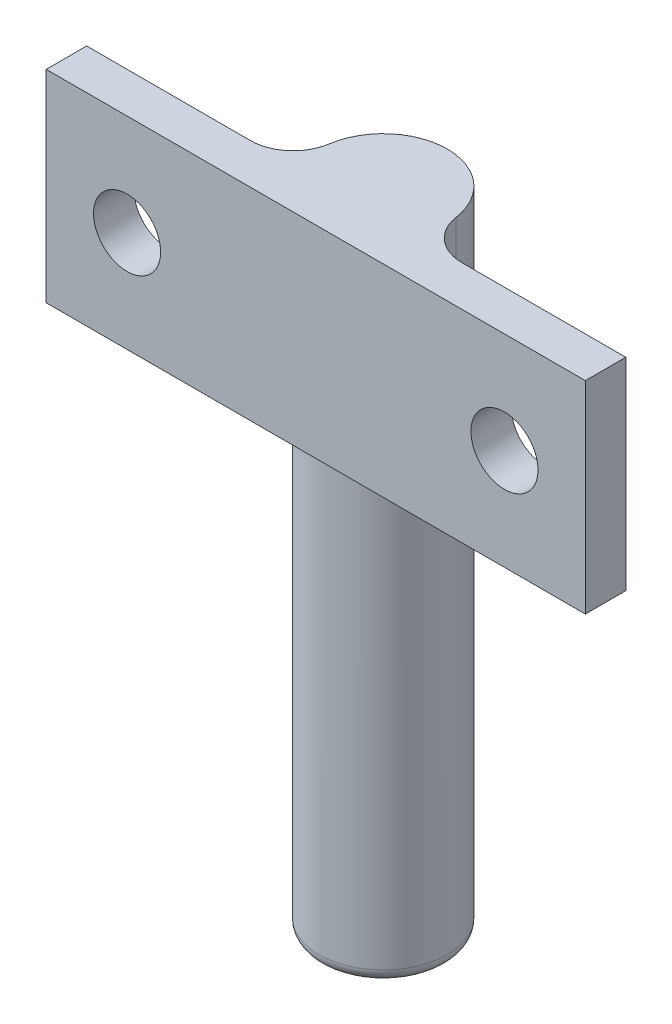
from build123d import *
from build123d.topology import SkipClean

# Parameters (mm, degrees)
BOSS_EXTRUDE1_DEPTH    = 15
FILLET1_R              = 3.175
SKETCH2_R              = 4.7625
BOSS_EXTRUDE2_DEPTH    = 33
FILLET2_R              = 1
F_10_CLEARANCE_HOLE1_D = 4.9784


with BuildPart() as part:
    # Sketch1 → Boss-Extrude1 (new body)
    with BuildSketch(Plane(origin=(0, 0, 0), x_dir=(1, 0, 0), z_dir=(0, 1, 0))):
        with BuildLine():
            Line((-20, 3), (-4.322199, 3))
            ThreePointArc((-4.322199, 3), (0, 9.7625), (4.322199, 3))
            Line((4.322199, 3), (20, 3))
            Line((20, 3), (20, 0))
            Line((20, 0), (-20, 0))
            Line((-20, 0), (-20, 3))
        make_face()
    extrude(amount=BOSS_EXTRUDE1_DEPTH)

    # Fillet1
    fillet1_edges = [part.edges().sort_by_distance(p)[0] for p in [
        (-4.322199, 7.5, -3),
        (4.322199, 7.5, -3),
    ]]
    fillet(fillet1_edges, radius=FILLET1_R)

    # Sketch2 → Boss-Extrude2 (add)
    with SkipClean():  # keep this step's faces unmerged: merging them makes the solid invalid here
        with BuildSketch(Plane.XZ):
            with Locations(Location((0, -5, 0), (0, 0, 270))):  # turned: the seam where the file's is
                Circle(SKETCH2_R)
        extrude(amount=BOSS_EXTRUDE2_DEPTH)

    # Fillet2
    fillet2_edges = [part.edges().sort_by_distance(p)[0] for p in [
        (0, -33, -0.2375),
    ]]
    fillet(fillet2_edges, radius=FILLET2_R)

    # #10 Clearance Hole1 (through all)
    with Locations(Plane(origin=(0, 0, -3), x_dir=(-1, 0, 0), z_dir=(0, 0, -1))):
        with Locations((14, 7.5), (-14, 7.5)):
            Hole(F_10_CLEARANCE_HOLE1_D / 2)


solid = part.part
